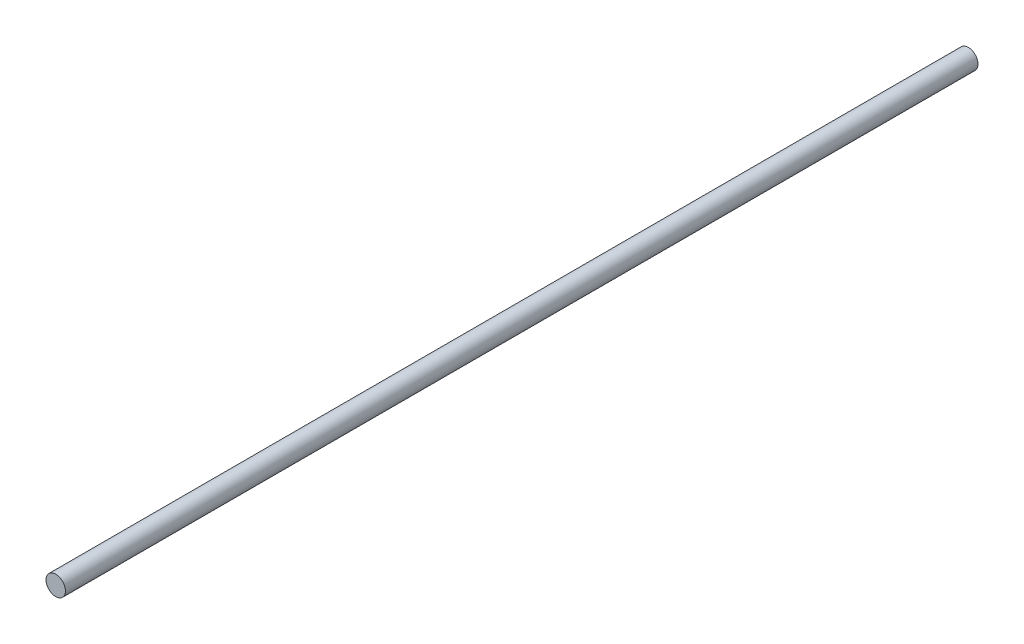
from build123d import *

# Parameters (mm, degrees)
SKETCH_1_R      = 4
EXTRUDE_1_DEPTH = 375


with BuildPart() as part:
    # 草图1 → 凸台-拉伸1 (new body)
    with BuildSketch(Plane.XY):
        Circle(SKETCH_1_R)
    extrude(amount=EXTRUDE_1_DEPTH)


solid = part.part
